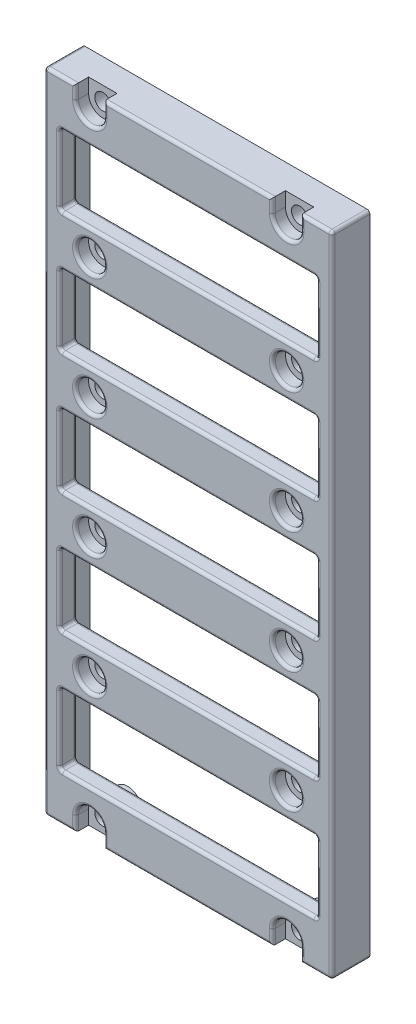
from build123d import *

# Parameters (mm, degrees)
BOSS_EXTRUDE1_DEPTH                            = 6.35
CBORE_FOR_2_SOCKET_HEAD_CAP_SCREW1_D           = 2.7051
CBORE_FOR_2_SOCKET_HEAD_CAP_SCREW1_CBORE_D     = 4.7625
CBORE_FOR_2_SOCKET_HEAD_CAP_SCREW1_CBORE_DEPTH = 2.1844
SKETCH4_W                                      = 4.7625
SKETCH4_H                                      = 2.3876
CUT_EXTRUDE1_DEPTH                             = 2.1844
SKETCH5_W                                      = 43.18
SKETCH5_H                                      = 11.90625
CUT_EXTRUDE2_DEPTH                             = 7.35
SKETCH6_R                                      = 2.38125
SKETCH6_W                                      = 43.18
SKETCH6_H                                      = 11.90625
CUT_EXTRUDE3_DEPTH                             = 3.4036
FILLET1_R                                      = 0.508
SKETCH7_W                                      = 39.926180477
SKETCH7_H                                      = 73.723340944
CUT_EXTRUDE4_DEPTH                             = 2.54


with BuildPart() as part:
    # Sketch1 → Boss-Extrude1 (new body)
    with BuildSketch(Plane.XY):
        Polygon((-15.24, -177.7842297), (-15.24, -72.1202297), (-15.24, -70.5962297), (-63.5, -70.5962297), (-63.5, -72.1202297), (-63.5, -177.7842297), (-63.5, -179.3082297), (-15.24, -179.3082297), align=None)
    extrude(amount=BOSS_EXTRUDE1_DEPTH)

    # CBORE for #2 Socket Head Cap Screw1 (through all)
    with Locations(Plane.XY.offset(6.35)):
        with Locations((-22.86, -72.9838297), (-22.86, -94.4722297), (-22.86, -114.7922297), (-22.86, -135.1122297), (-22.86, -155.4322297), (-22.86, -176.9206297), (-55.88, -176.9206297), (-55.88, -155.4322297), (-55.88, -135.1122297), (-55.88, -114.7922297), (-55.88, -94.4722297), (-55.88, -72.9838297)):
            CounterBoreHole(CBORE_FOR_2_SOCKET_HEAD_CAP_SCREW1_D / 2, CBORE_FOR_2_SOCKET_HEAD_CAP_SCREW1_CBORE_D / 2, CBORE_FOR_2_SOCKET_HEAD_CAP_SCREW1_CBORE_DEPTH)

    # Sketch4 → Cut-Extrude1 (cut)
    with BuildSketch(Plane.XY.offset(6.35)):
        with Locations((-22.86, -178.1144297)):
            Rectangle(SKETCH4_W, SKETCH4_H)
        with Locations((-55.88, -178.1144297)):
            Rectangle(SKETCH4_W, SKETCH4_H)
        with Locations((-22.86, -71.7900297)):
            Rectangle(SKETCH4_W, SKETCH4_H)
        with Locations((-55.88, -71.7900297)):
            Rectangle(SKETCH4_W, SKETCH4_H)
    extrude(amount=-CUT_EXTRUDE1_DEPTH, mode=Mode.SUBTRACT)

    # Sketch5 → Cut-Extrude2 (cut, through all)
    with BuildSketch(Plane.XY.offset(6.35)):
        with Locations((-39.37, -165.5922297)):
            Rectangle(SKETCH5_W, SKETCH5_H)
        with Locations((-39.37, -145.2722297)):
            Rectangle(SKETCH5_W, SKETCH5_H)
        with Locations((-39.37, -124.9522297)):
            Rectangle(SKETCH5_W, SKETCH5_H)
        with Locations((-39.37, -104.6322297)):
            Rectangle(SKETCH5_W, SKETCH5_H)
        with Locations((-39.37, -84.3122297)):
            Rectangle(SKETCH5_W, SKETCH5_H)
    extrude(amount=-CUT_EXTRUDE2_DEPTH, mode=Mode.SUBTRACT)

    # Sketch6 → Cut-Extrude3 (cut)
    with BuildSketch(Plane(origin=(0, 0, 0), x_dir=(-1, 0, 0), z_dir=(0, 0, -1))):
        with BuildLine():
            Line((20.47875, -72.9838297), (20.47875, -71.8662297))
            Line((20.47875, -71.8662297), (16.51, -71.8662297))
            Line((16.51, -71.8662297), (16.51, -178.0382297))
            Line((16.51, -178.0382297), (20.47875, -178.0382297))
            Line((20.47875, -178.0382297), (20.47875, -176.9206297))
            ThreePointArc((20.47875, -176.9206297), (22.86, -174.5393797), (25.24125, -176.9206297))
            Line((25.24125, -176.9206297), (25.24125, -178.0382297))
            Line((25.24125, -178.0382297), (53.49875, -178.0382297))
            Line((53.49875, -178.0382297), (53.49875, -176.9206297))
            ThreePointArc((53.49875, -176.9206297), (55.88, -174.5393797), (58.26125, -176.9206297))
            Line((58.26125, -176.9206297), (58.26125, -178.0382297))
            Line((58.26125, -178.0382297), (62.23, -178.0382297))
            Line((62.23, -178.0382297), (62.23, -71.8662297))
            Line((62.23, -71.8662297), (58.26125, -71.8662297))
            Line((58.26125, -71.8662297), (58.26125, -72.9838297))
            ThreePointArc((58.26125, -72.9838297), (55.88, -75.3650797), (53.49875, -72.9838297))
            Line((53.49875, -72.9838297), (53.49875, -71.8662297))
            Line((53.49875, -71.8662297), (25.24125, -71.8662297))
            Line((25.24125, -71.8662297), (25.24125, -72.9838297))
            ThreePointArc((25.24125, -72.9838297), (22.86, -75.3650797), (20.47875, -72.9838297))
        make_face()
        with Locations((55.88, -155.4322297)):
            Circle(SKETCH6_R, mode=Mode.SUBTRACT)
        with Locations((22.86, -155.4322297)):
            Circle(SKETCH6_R, mode=Mode.SUBTRACT)
        with Locations((22.86, -135.1122297)):
            Circle(SKETCH6_R, mode=Mode.SUBTRACT)
        with Locations((55.88, -135.1122297)):
            Circle(SKETCH6_R, mode=Mode.SUBTRACT)
        with Locations((55.88, -114.7922297)):
            Circle(SKETCH6_R, mode=Mode.SUBTRACT)
        with Locations((22.86, -114.7922297)):
            Circle(SKETCH6_R, mode=Mode.SUBTRACT)
        with Locations((22.86, -94.4722297)):
            Circle(SKETCH6_R, mode=Mode.SUBTRACT)
        with Locations((55.88, -94.4722297)):
            Circle(SKETCH6_R, mode=Mode.SUBTRACT)
        with Locations((39.37, -104.6322297)):
            Rectangle(SKETCH6_W, SKETCH6_H, mode=Mode.SUBTRACT)
        with Locations((39.37, -84.3122297)):
            Rectangle(SKETCH6_W, SKETCH6_H, mode=Mode.SUBTRACT)
        with Locations((39.37, -124.9522297)):
            Rectangle(SKETCH6_W, SKETCH6_H, mode=Mode.SUBTRACT)
        with Locations((39.37, -145.2722297)):
            Rectangle(SKETCH6_W, SKETCH6_H, mode=Mode.SUBTRACT)
        with Locations((39.37, -165.5922297)):
            Rectangle(SKETCH6_W, SKETCH6_H, mode=Mode.SUBTRACT)
    extrude(amount=-CUT_EXTRUDE3_DEPTH, mode=Mode.SUBTRACT)

    # Fillet1
    fillet1_edges = [part.edges().sort_by_distance(p)[0] for p in [
        (-25.24125, -114.7922297, 6.35),
        (-25.24125, -94.4722297, 6.35),
        (-17.859375, -70.5962297, 6.35),
        (-17.859375, -179.3082297, 6.35),
        (-15.24, -179.3082297, 3.175),
        (-25.24125, -178.1144297, 6.35),
        (-20.47875, -178.1144297, 6.35),
        (-63.5, -179.3082297, 3.175),
        (-63.5, -70.5962297, 3.175),
        (-15.24, -70.5962297, 3.175),
        (-39.37, -179.3082297, 6.35),
        (-53.49875, -178.1144297, 6.35),
        (-58.26125, -178.1144297, 6.35),
        (-63.5, -124.9522297, 6.35),
        (-22.86, -75.3650797, 6.35),
        (-39.37, -70.5962297, 6.35),
        (-25.24125, -71.7900297, 6.35),
        (-20.47875, -71.7900297, 6.35),
        (-55.88, -75.3650797, 6.35),
        (-60.880625, -70.5962297, 6.35),
        (-58.26125, -71.7900297, 6.35),
        (-53.49875, -71.7900297, 6.35),
        (-17.78, -165.5922297, 6.35),
        (-39.37, -159.6391047, 6.35),
        (-60.96, -165.5922297, 6.35),
        (-39.37, -171.5453547, 6.35),
        (-39.37, -151.2253547, 6.35),
        (-17.78, -145.2722297, 6.35),
        (-39.37, -139.3191047, 6.35),
        (-60.96, -145.2722297, 6.35),
        (-39.37, -130.9053547, 6.35),
        (-17.78, -124.9522297, 6.35),
        (-39.37, -118.9991047, 6.35),
        (-60.96, -124.9522297, 6.35),
        (-39.37, -110.5853547, 6.35),
        (-17.78, -104.6322297, 6.35),
        (-39.37, -98.6791047, 6.35),
        (-60.96, -104.6322297, 6.35),
        (-60.880625, -179.3082297, 6.35),
        (-39.37, -90.2653547, 6.35),
        (-17.78, -84.3122297, 6.35),
        (-39.37, -78.3591047, 6.35),
        (-60.96, -84.3122297, 6.35),
        (-17.78, -78.3591047, 4.8768),
        (-17.78, -90.2653547, 4.8768),
        (-60.96, -78.3591047, 4.8768),
        (-60.96, -90.2653547, 4.8768),
        (-17.78, -98.6791047, 4.8768),
        (-17.78, -110.5853547, 4.8768),
        (-60.96, -98.6791047, 4.8768),
        (-60.96, -110.5853547, 4.8768),
        (-17.78, -118.9991047, 4.8768),
        (-17.78, -130.9053547, 4.8768),
        (-60.96, -118.9991047, 4.8768),
        (-60.96, -130.9053547, 4.8768),
        (-17.78, -139.3191047, 4.8768),
        (-17.78, -151.2253547, 4.8768),
        (-60.96, -139.3191047, 4.8768),
        (-60.96, -151.2253547, 4.8768),
        (-60.96, -159.6391047, 4.8768),
        (-17.78, -159.6391047, 4.8768),
        (-60.96, -171.5453547, 4.8768),
        (-17.78, -171.5453547, 4.8768),
        (-20.47875, -71.8662297, 1.7018),
        (-16.51, -71.8662297, 1.7018),
        (-16.51, -178.0382297, 1.7018),
        (-20.47875, -178.0382297, 1.7018),
        (-25.24125, -178.0382297, 1.7018),
        (-53.49875, -178.0382297, 1.7018),
        (-58.26125, -178.0382297, 1.7018),
        (-62.23, -178.0382297, 1.7018),
        (-62.23, -71.8662297, 1.7018),
        (-58.26125, -71.8662297, 1.7018),
        (-53.49875, -71.8662297, 1.7018),
        (-25.24125, -71.8662297, 1.7018),
        (-53.49875, -155.4322297, 3.4036),
        (-20.47875, -155.4322297, 3.4036),
        (-20.47875, -135.1122297, 3.4036),
        (-53.49875, -135.1122297, 3.4036),
        (-53.49875, -114.7922297, 3.4036),
        (-20.47875, -114.7922297, 3.4036),
        (-20.47875, -94.4722297, 3.4036),
        (-53.49875, -94.4722297, 3.4036),
        (-39.37, -98.6791047, 3.4036),
        (-17.78, -104.6322297, 3.4036),
        (-39.37, -110.5853547, 3.4036),
        (-60.96, -104.6322297, 3.4036),
        (-39.37, -78.3591047, 3.4036),
        (-17.78, -84.3122297, 3.4036),
        (-39.37, -90.2653547, 3.4036),
        (-60.96, -84.3122297, 3.4036),
        (-39.37, -118.9991047, 3.4036),
        (-17.78, -124.9522297, 3.4036),
        (-39.37, -130.9053547, 3.4036),
        (-60.96, -124.9522297, 3.4036),
        (-39.37, -139.3191047, 3.4036),
        (-17.78, -145.2722297, 3.4036),
        (-39.37, -151.2253547, 3.4036),
        (-60.96, -145.2722297, 3.4036),
        (-60.96, -165.5922297, 3.4036),
        (-39.37, -159.6391047, 3.4036),
        (-17.78, -165.5922297, 3.4036),
        (-39.37, -171.5453547, 3.4036),
        (-22.86, -75.3650797, 3.4036),
        (-25.24125, -72.4250297, 3.4036),
        (-39.37, -71.8662297, 3.4036),
        (-53.49875, -72.4250297, 3.4036),
        (-55.88, -75.3650797, 3.4036),
        (-58.26125, -72.4250297, 3.4036),
        (-60.245625, -71.8662297, 3.4036),
        (-62.23, -124.9522297, 3.4036),
        (-60.245625, -178.0382297, 3.4036),
        (-58.26125, -177.4794297, 3.4036),
        (-55.88, -174.5393797, 3.4036),
        (-53.49875, -177.4794297, 3.4036),
        (-39.37, -178.0382297, 3.4036),
        (-25.24125, -177.4794297, 3.4036),
        (-22.86, -174.5393797, 3.4036),
        (-20.47875, -177.4794297, 3.4036),
        (-18.494375, -178.0382297, 3.4036),
        (-16.51, -124.9522297, 3.4036),
        (-18.494375, -71.8662297, 3.4036),
        (-20.47875, -72.4250297, 3.4036),
        (-58.26125, -94.4722297, 6.35),
        (-15.24, -124.9522297, 6.35),
        (-58.26125, -114.7922297, 6.35),
        (-58.26125, -135.1122297, 6.35),
        (-58.26125, -155.4322297, 6.35),
        (-55.88, -174.5393797, 6.35),
        (-22.86, -174.5393797, 6.35),
        (-25.24125, -155.4322297, 6.35),
        (-25.24125, -135.1122297, 6.35),
    ]]
    fillet(fillet1_edges, radius=FILLET1_R)

    # Sketch7 → Cut-Extrude4 (cut)
    with BuildSketch(Plane(origin=(0, 0, 0), x_dir=(-1, 0, 0), z_dir=(0, 0, -1))):
        with Locations((39.544664201, -125.057111299)):
            Rectangle(SKETCH7_W, SKETCH7_H)
    extrude(amount=-CUT_EXTRUDE4_DEPTH, mode=Mode.SUBTRACT)


solid = part.part
